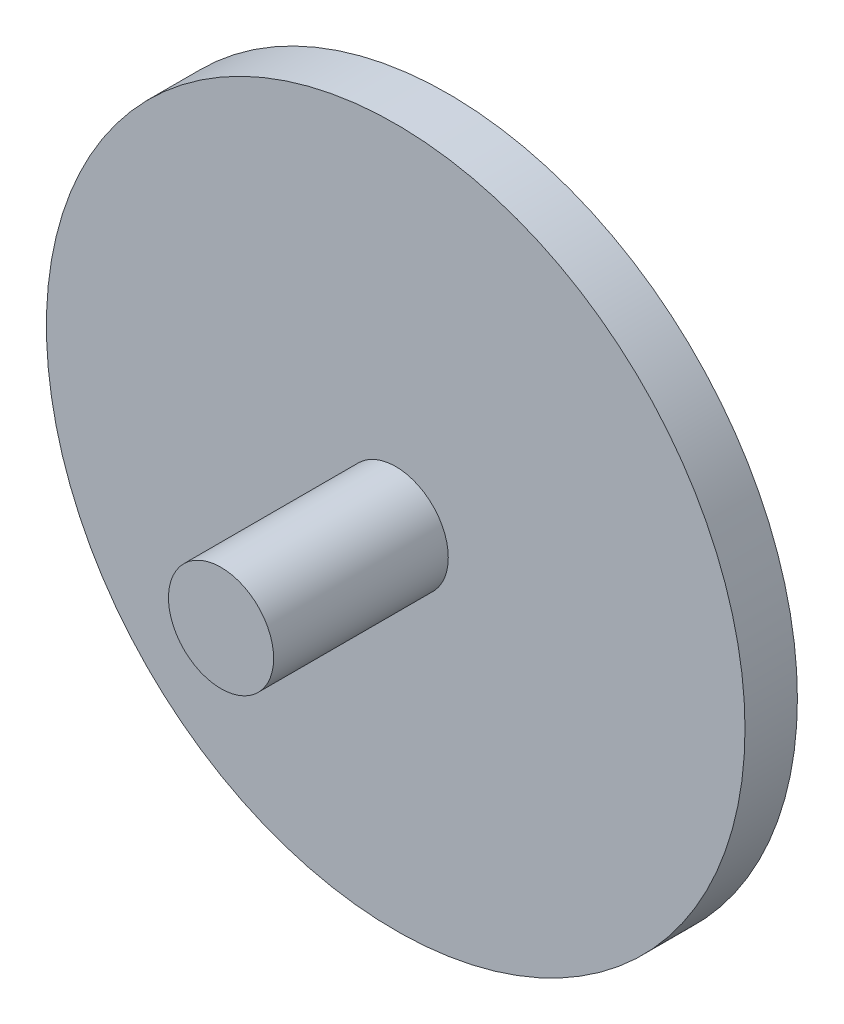
from build123d import *

# Parameters (mm, degrees)
CROQUIS1_R              = 10
SALIENTE_EXTRUIR1_DEPTH = 1.5
CROQUIS3_R              = 1.505357488
SALIENTE_EXTRUIR2_DEPTH = 5


with BuildPart() as part:
    # Croquis1 → Saliente-Extruir1 (new body)
    with BuildSketch(Plane.XY):
        Circle(CROQUIS1_R)
    extrude(amount=SALIENTE_EXTRUIR1_DEPTH)

    # Croquis3 → Saliente-Extruir2 (add)
    with BuildSketch(Plane.XY.offset(1.5)):
        Circle(CROQUIS3_R)
    extrude(amount=SALIENTE_EXTRUIR2_DEPTH)


solid = part.part
